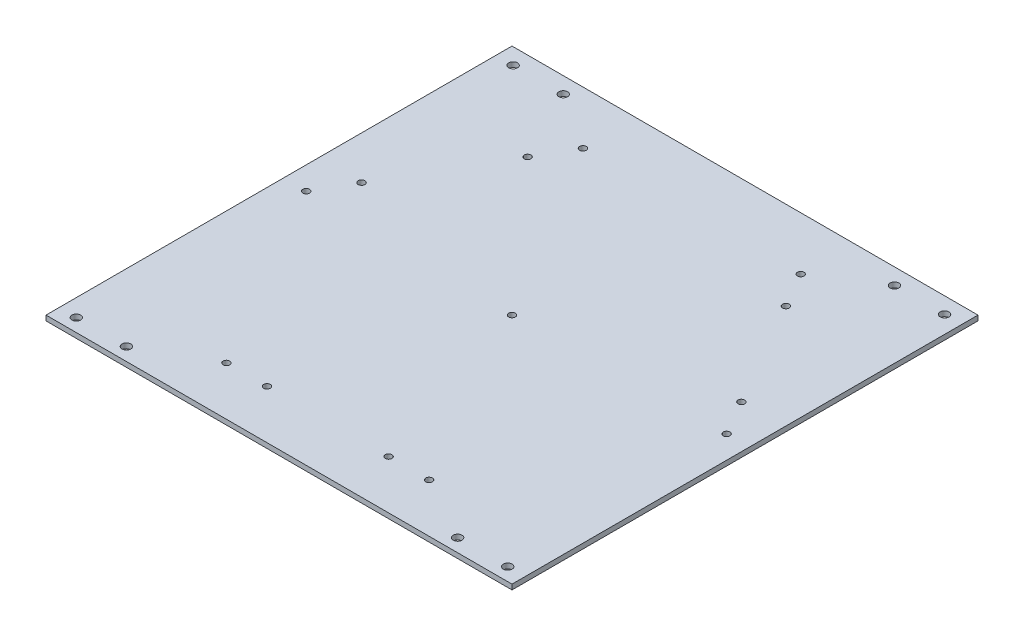
from build123d import *

# Parameters (mm, degrees)
SKETCH1_W                = 292.1
SKETCH1_H                = 292.1
BOSS_EXTRUDE1_DEPTH      = 3.175
M5X0_8_TAPPED_HOLE2_D    = 4.2
M5_CLEARANCE_HOLE1_D     = 5.5
M5_CLEARANCE_HOLE1_DEPTH = 25.4
M5_CLEARANCE_HOLE1_TIP   = 1.652366702


with BuildPart() as part:
    # Sketch1 → Boss-Extrude1 (new body)
    with BuildSketch(Plane(origin=(0, 0, 0), x_dir=(1, 0, 0), z_dir=(0, 1, 0))):
        Rectangle(SKETCH1_W, SKETCH1_H)
    extrude(amount=BOSS_EXTRUDE1_DEPTH)

    # M5x0.8 Tapped Hole2 (through all)
    with Locations(Plane(origin=(0, 3.175, 0), x_dir=(1, 0, 0), z_dir=(0, 1, 0))):
        with Locations((-63.5, -115.484487595), (-38.1, -115.484487595), (38.1, -115.484487595), (63.5, -115.484487595), (-68.2625, 112.734856938), (-80.9625, 90.737811682), (-119.0625, 24.746675913), (-131.7625, 2.749630657), (131.7625, 2.749630657), (119.0625, 24.746675913), (80.9625, 90.737811682), (68.2625, 112.734856938), (0, 0)):
            Hole(M5X0_8_TAPPED_HOLE2_D / 2)

    # M5 Clearance Hole1
    with Locations(Plane(origin=(0, 3.175, 0), x_dir=(1, 0, 0), z_dir=(0, 1, 0))):
        with Locations((-135.216191685, -137.892013655), (-103.802039507, -137.892013655), (103.802039507, -137.892013655), (135.216191685, -137.892013655), (103.802039507, 135.926865034), (135.216191685, 135.926865034), (-135.216191685, 135.926865034), (-103.802039507, 135.926865034)):
            Hole(M5_CLEARANCE_HOLE1_D / 2, depth=M5_CLEARANCE_HOLE1_DEPTH)
            with Locations((0, 0, -(M5_CLEARANCE_HOLE1_DEPTH + M5_CLEARANCE_HOLE1_TIP / 2))):  # 118° drill point
                Cone(0, M5_CLEARANCE_HOLE1_D / 2, M5_CLEARANCE_HOLE1_TIP, mode=Mode.SUBTRACT)


solid = part.part
